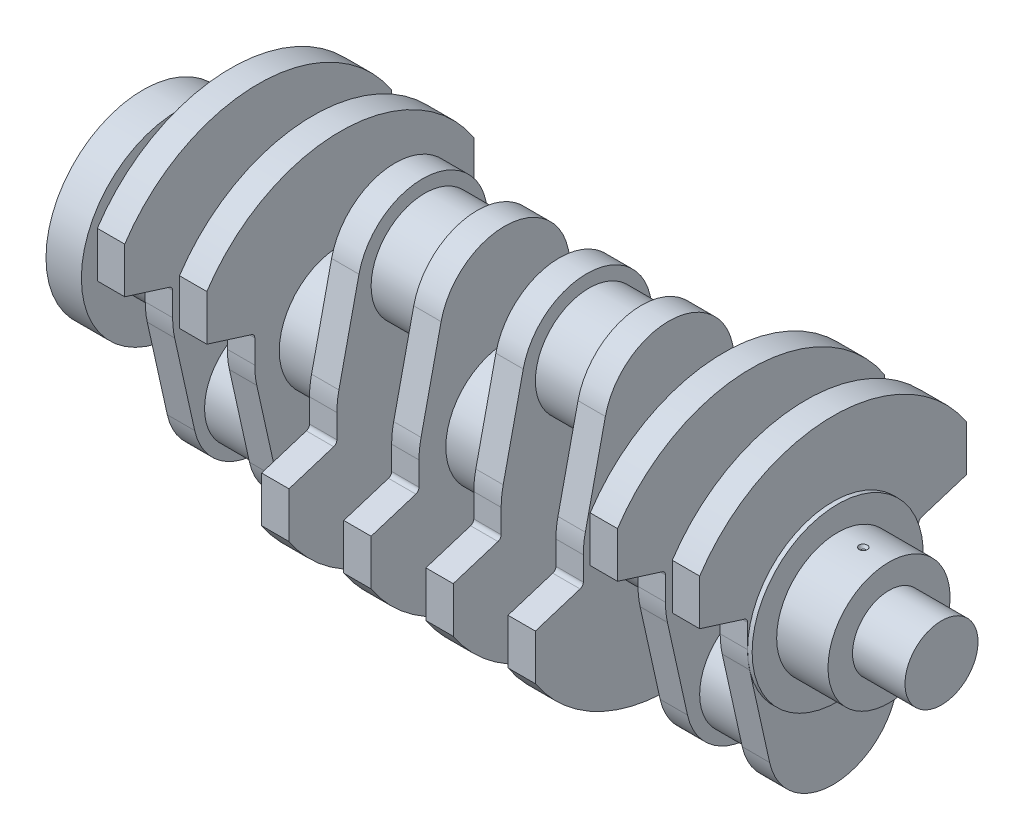
from build123d import *

# Parameters (mm, degrees)
ESBO_O1_R        = 16
EXTRUS_O1_DEPTH  = 23
ESBO_O2_R        = 26.75
EXTRUS_O2_DEPTH  = 22.5
EXTRUS_O4_DEPTH  = 12
FILETE1_R        = 2
FILETE2_R        = 2
ESBO_O10_R       = 23.5
EXTRUS_O7_DEPTH  = 23
EXTRUS_O8_DEPTH  = 12
EXTRUS_O14_DEPTH = 12
EXTRUS_O15_DEPTH = 12
EXTRUS_O16_DEPTH = 12
EXTRUS_O17_DEPTH = 12
ESBO_O20_R       = 26.75
EXTRUS_O18_DEPTH = 23
ESBO_O21_R       = 23.5
EXTRUS_O19_DEPTH = 23
ESBO_O22_R       = 26.75
EXTRUS_O21_DEPTH = 23
ESBO_O23_R       = 23.5
EXTRUS_O22_DEPTH = 23
EXTRUS_O23_DEPTH = 12
EXTRUS_O24_DEPTH = 12
ESBO_O27_R       = 26.75
EXTRUS_O25_DEPTH = 24
ESBO_O28_R       = 23.5
EXTRUS_O26_DEPTH = 24
ESBO_O29_R       = 26.75
EXTRUS_O27_DEPTH = 23
ESBO_O30_R       = 42.5
EXTRUS_O28_DEPTH = 15.5
ESBO_O31_R       = 21.5
EXTRUS_O29_DEPTH = 5.5
ESBO_O33_R       = 15
EXTRUS_O34_DEPTH = 7
EXTRUS_O34_DRAFT = 42
ESBO_O34_R       = 8
EXTRUS_O35_DEPTH = 25
ESBO_O41_R       = 37.5
EXTRUS_O42_DEPTH = 2


with BuildPart() as part:
    # Esboço1 → Extrusão1 (new body)
    with BuildSketch(Plane(origin=(0, 0, 0), x_dir=(0, 0, -1), z_dir=(1, 0, 0))):
        Circle(ESBO_O1_R)
    extrude(amount=-EXTRUS_O1_DEPTH)

    # Esboço2 → Extrusão2 (add)
    with BuildSketch(Plane.ZY.offset(23)):
        Circle(ESBO_O2_R)
    extrude(amount=EXTRUS_O2_DEPTH)

    # Esboço40 → Corte-Revolução3 (revolve, cut)
    with BuildSketch(Plane.XY, mode=Mode.PRIVATE) as corte_revolu_o3_sk:
        Polygon((-34.25, 27.978873535), (-34.25, 25.360775751), (-33.25, 25.360775751), (-31.75, 27.978873535), align=None)
    revolve(corte_revolu_o3_sk.sketch.rotate(Axis((-34.25, 27.978873535, 0), (0, -1, 0)), 90), axis=Axis((-34.25, 27.978873535, 0), (0, -1, 0)), mode=Mode.SUBTRACT)  # turned: the seam where the file's is

    # Esboço41 → Extrusão42 (add)
    with BuildSketch(Plane.ZY.offset(45.5)):
        Circle(ESBO_O41_R)
    extrude(amount=EXTRUS_O42_DEPTH)


with BuildPart() as body_2:
    # Esboço5 → Extrusão4 (new body)
    with BuildSketch(Plane.ZY.offset(47.5)):
        with BuildLine():
            Line((-36.607539576, -8.13253012), (-27.821730078, -47.680722892))
            ThreePointArc((-27.821730078, -47.680722892), (0, -70), (27.821730078, -47.680722892))
            Line((27.821730078, -47.680722892), (36.607539576, -8.13253012))
            ThreePointArc((36.607539576, -8.13253012), (37.276217177, -4.090676343), (37.5, 0))
            Line((37.5, 0), (37.5, 11.821483345))
            Line((37.5, 11.821483345), (58.5, 18.441514018))
            Line((58.5, 18.441514018), (58.5, 38.441514018))
            ThreePointArc((58.5, 38.441514018), (0, 70), (-58.5, 38.441514018))
            Line((-58.5, 38.441514018), (-58.5, 18.441514018))
            Line((-58.5, 18.441514018), (-37.5, 11.821483345))
            Line((-37.5, 11.821483345), (-37.5, 0))
            ThreePointArc((-37.5, 0), (-37.276217177, -4.090676343), (-36.607539576, -8.13253012))
        make_face()
    extrude(amount=EXTRUS_O4_DEPTH)

    # Filete1
    filete1_edges = [body_2.edges().sort_by_distance(p)[0] for p in [
        (-53.5, 11.821483345, -37.5),
    ]]
    fillet(filete1_edges, radius=FILETE1_R)

    # Filete2
    filete2_edges = [body_2.edges().sort_by_distance(p)[0] for p in [
        (-53.5, 11.821483345, 37.5),
    ]]
    fillet(filete2_edges, radius=FILETE2_R)

    # Esboço10 → Extrusão7 (add)
    with BuildSketch(Plane.ZY.offset(59.5)):
        with Locations((0, -41.5)):
            Circle(ESBO_O10_R)
    extrude(amount=EXTRUS_O7_DEPTH)


with BuildPart() as body_3:
    # Esboço9 → Extrusão8 (new body)
    with BuildSketch(Plane.ZY.offset(83.5)):
        with BuildLine():
            Line((27.821730078, -47.680722892), (36.607539576, -8.13253012))
            ThreePointArc((36.607539576, -8.13253012), (37.276217177, -4.090676343), (37.5, 0))
            Line((37.5, 0), (37.5, 10.354939827))
            ThreePointArc((37.5, 10.354939827), (37.887142651, 11.537602573), (38.89869117, 12.262406128))
            Line((38.89869117, 12.262406128), (58.5, 18.441514018))
            Line((58.5, 18.441514018), (58.5, 38.441514018))
            ThreePointArc((58.5, 38.441514018), (0, 70), (-58.5, 38.441514018))
            Line((-58.5, 38.441514018), (-58.5, 18.441514018))
            Line((-58.5, 18.441514018), (-38.89869117, 12.262406128))
            ThreePointArc((-38.89869117, 12.262406128), (-37.887142651, 11.537602573), (-37.5, 10.354939827))
            Line((-37.5, 10.354939827), (-37.5, 0))
            ThreePointArc((-37.5, 0), (-37.276217177, -4.090676343), (-36.607539576, -8.13253012))
            Line((-36.607539576, -8.13253012), (-27.821730078, -47.680722892))
            ThreePointArc((-27.821730078, -47.680722892), (0, -70), (27.821730078, -47.680722892))
        make_face()
    extrude(amount=EXTRUS_O8_DEPTH)


with BuildPart() as body_4:
    # Esboço16 → Extrusão14 (new body)
    with BuildSketch(Plane.ZY.offset(119.5)):
        with BuildLine():
            Line((37.5, 0), (37.5, -10.354939827))
            ThreePointArc((37.5, -10.354939827), (37.887142651, -11.537602573), (38.89869117, -12.262406128))
            Line((38.89869117, -12.262406128), (58.5, -18.441514018))
            Line((58.5, -18.441514018), (58.5, -38.441514018))
            ThreePointArc((58.5, -38.441514018), (0, -70), (-58.5, -38.441514018))
            Line((-58.5, -38.441514018), (-58.5, -18.441514018))
            Line((-58.5, -18.441514018), (-38.89869117, -12.262406128))
            ThreePointArc((-38.89869117, -12.262406128), (-37.887142651, -11.537602573), (-37.5, -10.354939827))
            Line((-37.5, -10.354939827), (-37.5, 0))
            ThreePointArc((-37.5, 0), (-37.276217177, 4.090676343), (-36.607539576, 8.13253012))
            Line((-36.607539576, 8.13253012), (-27.821730078, 47.680722892))
            ThreePointArc((-27.821730078, 47.680722892), (0, 70), (27.821730078, 47.680722892))
            Line((27.821730078, 47.680722892), (36.607539576, 8.13253012))
            ThreePointArc((36.607539576, 8.13253012), (37.276217177, 4.090676343), (37.5, 0))
        make_face()
    extrude(amount=EXTRUS_O14_DEPTH)


with BuildPart() as body_5:
    # Esboço17 → Extrusão15 (new body)
    with BuildSketch(Plane.ZY.offset(155.5)):
        with BuildLine():
            Line((-38.89869117, -12.262406128), (-58.5, -18.441514018))
            Line((-58.5, -18.441514018), (-58.5, -38.441514018))
            ThreePointArc((-58.5, -38.441514018), (0, -70), (58.5, -38.441514018))
            Line((58.5, -38.441514018), (58.5, -18.441514018))
            Line((58.5, -18.441514018), (38.89869117, -12.262406128))
            ThreePointArc((38.89869117, -12.262406128), (37.887142651, -11.537602573), (37.5, -10.354939827))
            Line((37.5, -10.354939827), (37.5, 0))
            ThreePointArc((37.5, 0), (37.276217177, 4.090676343), (36.607539576, 8.13253012))
            Line((36.607539576, 8.13253012), (27.821730078, 47.680722892))
            ThreePointArc((27.821730078, 47.680722892), (0, 70), (-27.821730078, 47.680722892))
            Line((-27.821730078, 47.680722892), (-36.607539576, 8.13253012))
            ThreePointArc((-36.607539576, 8.13253012), (-37.276217177, 4.090676343), (-37.5, 0))
            Line((-37.5, 0), (-37.5, -10.354939827))
            ThreePointArc((-37.5, -10.354939827), (-37.887142651, -11.537602573), (-38.89869117, -12.262406128))
        make_face()
    extrude(amount=EXTRUS_O15_DEPTH)


with BuildPart() as body_6:
    # Esboço18 → Extrusão16 (new body)
    with BuildSketch(Plane.ZY.offset(191.5)):
        with BuildLine():
            Line((-38.89869117, -12.262406128), (-58.5, -18.441514018))
            Line((-58.5, -18.441514018), (-58.5, -38.441514018))
            ThreePointArc((-58.5, -38.441514018), (0, -70), (58.5, -38.441514018))
            Line((58.5, -38.441514018), (58.5, -18.441514018))
            Line((58.5, -18.441514018), (38.89869117, -12.262406128))
            ThreePointArc((38.89869117, -12.262406128), (37.887142651, -11.537602573), (37.5, -10.354939827))
            Line((37.5, -10.354939827), (37.5, 0))
            ThreePointArc((37.5, 0), (37.276217177, 4.090676343), (36.607539576, 8.13253012))
            Line((36.607539576, 8.13253012), (27.821730078, 47.680722892))
            ThreePointArc((27.821730078, 47.680722892), (0, 70), (-27.821730078, 47.680722892))
            Line((-27.821730078, 47.680722892), (-36.607539576, 8.13253012))
            ThreePointArc((-36.607539576, 8.13253012), (-37.276217177, 4.090676343), (-37.5, 0))
            Line((-37.5, 0), (-37.5, -10.354939827))
            ThreePointArc((-37.5, -10.354939827), (-37.887142651, -11.537602573), (-38.89869117, -12.262406128))
        make_face()
    extrude(amount=EXTRUS_O16_DEPTH)


with BuildPart() as body_7:
    # Esboço19 → Extrusão17 (new body)
    with BuildSketch(Plane.ZY.offset(227.5)):
        with BuildLine():
            Line((-38.89869117, -12.262406128), (-58.5, -18.441514018))
            Line((-58.5, -18.441514018), (-58.5, -38.441514018))
            ThreePointArc((-58.5, -38.441514018), (0, -70), (58.5, -38.441514018))
            Line((58.5, -38.441514018), (58.5, -18.441514018))
            Line((58.5, -18.441514018), (38.89869117, -12.262406128))
            ThreePointArc((38.89869117, -12.262406128), (37.887142651, -11.537602573), (37.5, -10.354939827))
            Line((37.5, -10.354939827), (37.5, 0))
            ThreePointArc((37.5, 0), (37.276217177, 4.090676343), (36.607539576, 8.13253012))
            Line((36.607539576, 8.13253012), (27.821730078, 47.680722892))
            ThreePointArc((27.821730078, 47.680722892), (0, 70), (-27.821730078, 47.680722892))
            Line((-27.821730078, 47.680722892), (-36.607539576, 8.13253012))
            ThreePointArc((-36.607539576, 8.13253012), (-37.276217177, 4.090676343), (-37.5, 0))
            Line((-37.5, 0), (-37.5, -10.354939827))
            ThreePointArc((-37.5, -10.354939827), (-37.887142651, -11.537602573), (-38.89869117, -12.262406128))
        make_face()
    extrude(amount=EXTRUS_O17_DEPTH)


with BuildPart() as body_8:
    # Esboço20 → Extrusão18 (new body)
    with BuildSketch(Plane.ZY.offset(95.5)):
        Circle(ESBO_O20_R)
    extrude(amount=EXTRUS_O18_DEPTH)


with BuildPart() as body_9:
    # Esboço21 → Extrusão19 (new body)
    with BuildSketch(Plane.ZY.offset(131.5)):
        with Locations((0, 41.5)):
            Circle(ESBO_O21_R)
    extrude(amount=EXTRUS_O19_DEPTH)


with BuildPart() as body_10:
    # Esboço22 → Extrusão21 (new body)
    with BuildSketch(Plane.ZY.offset(167.5)):
        Circle(ESBO_O22_R)
    extrude(amount=EXTRUS_O21_DEPTH)


with BuildPart() as body_11:
    # Esboço23 → Extrusão22 (new body)
    with BuildSketch(Plane.ZY.offset(203.5)):
        with Locations((0, 41.5)):
            Circle(ESBO_O23_R)
    extrude(amount=EXTRUS_O22_DEPTH)


with BuildPart() as body_12:
    # Esboço25 → Extrusão23 (new body)
    with BuildSketch(Plane.ZY.offset(263.5)):
        with BuildLine():
            Line((58.5, 38.441514018), (58.5, 18.441514018))
            Line((58.5, 18.441514018), (38.89869117, 12.262406128))
            ThreePointArc((38.89869117, 12.262406128), (37.887142651, 11.537602573), (37.5, 10.354939827))
            Line((37.5, 10.354939827), (37.5, 0))
            ThreePointArc((37.5, 0), (37.276217177, -4.090676343), (36.607539576, -8.13253012))
            Line((36.607539576, -8.13253012), (27.821730078, -47.680722892))
            ThreePointArc((27.821730078, -47.680722892), (0, -70), (-27.821730078, -47.680722892))
            Line((-27.821730078, -47.680722892), (-36.607539576, -8.13253012))
            ThreePointArc((-36.607539576, -8.13253012), (-37.276217177, -4.090676343), (-37.5, 0))
            Line((-37.5, 0), (-37.5, 10.354939827))
            ThreePointArc((-37.5, 10.354939827), (-37.887142651, 11.537602573), (-38.89869117, 12.262406128))
            Line((-38.89869117, 12.262406128), (-58.5, 18.441514018))
            Line((-58.5, 18.441514018), (-58.5, 38.441514018))
            ThreePointArc((-58.5, 38.441514018), (0, 70), (58.5, 38.441514018))
        make_face()
    extrude(amount=EXTRUS_O23_DEPTH)

    # Esboço27 → Extrusão25 (add)
    with BuildSketch(Plane.ZY.offset(239.5)):
        Circle(ESBO_O27_R)
    extrude(amount=EXTRUS_O25_DEPTH)



with BuildPart() as body_13:
    # Esboço26 → Extrusão24 (new body)
    with BuildSketch(Plane.ZY.offset(299.5)):
        with BuildLine():
            Line((-58.5, 38.441514018), (-58.5, 18.441514018))
            Line((-58.5, 18.441514018), (-38.89869117, 12.262406128))
            ThreePointArc((-38.89869117, 12.262406128), (-37.887142651, 11.537602573), (-37.5, 10.354939827))
            Line((-37.5, 10.354939827), (-37.5, 0))
            ThreePointArc((-37.5, 0), (-37.276217177, -4.090676343), (-36.607539576, -8.13253012))
            Line((-36.607539576, -8.13253012), (-27.821730078, -47.680722892))
            ThreePointArc((-27.821730078, -47.680722892), (0, -70), (27.821730078, -47.680722892))
            Line((27.821730078, -47.680722892), (36.607539576, -8.13253012))
            ThreePointArc((36.607539576, -8.13253012), (37.276217177, -4.090676343), (37.5, 0))
            Line((37.5, 0), (37.5, 10.354939827))
            ThreePointArc((37.5, 10.354939827), (37.887142651, 11.537602573), (38.89869117, 12.262406128))
            Line((38.89869117, 12.262406128), (58.5, 18.441514018))
            Line((58.5, 18.441514018), (58.5, 38.441514018))
            ThreePointArc((58.5, 38.441514018), (0, 70), (-58.5, 38.441514018))
        make_face()
    extrude(amount=EXTRUS_O24_DEPTH)


with BuildPart() as body_12_1:
    add(body_12.part)

    add(body_13.part)  # Extrusão26 merges body 13
    # Esboço28 → Extrusão26 (add)
    with BuildSketch(Plane.ZY.offset(275.5)):
        with Locations(Location((0, -41.5, 0), (0, 0, 180))):  # turned: the seam where the file's is
            Circle(ESBO_O28_R)
    extrude(amount=EXTRUS_O26_DEPTH)

    # Esboço29 → Extrusão27 (add)
    with BuildSketch(Plane.ZY.offset(311.5)):
        Circle(ESBO_O29_R)
    extrude(amount=EXTRUS_O27_DEPTH)

    # Esboço30 → Extrusão28 (add)
    with BuildSketch(Plane.ZY.offset(334.5)):
        Circle(ESBO_O30_R)
    extrude(amount=EXTRUS_O28_DEPTH)

    # Esboço31 → Extrusão29 (add)
    with BuildSketch(Plane.ZY.offset(350)):
        Circle(ESBO_O31_R)
    extrude(amount=EXTRUS_O29_DEPTH)


with BuildPart() as extrus_o34_tool:
    # Esboço33 → Extrusão34 (with draft: the straight prism first)
    with BuildSketch(Plane.ZY.offset(362.5)):
        Circle(ESBO_O33_R)
    extrude(amount=-EXTRUS_O34_DEPTH)
    # Extrusão34: the draft: its side faces are tilted about the plane it starts from
    extrus_o34_sides = [extrus_o34_tool.faces().sort_by_distance(p)[0] for p in [
        (-359, 0, -15),
    ]]
    draft(extrus_o34_sides, Plane.ZY.offset(362.5), EXTRUS_O34_DRAFT)


with BuildPart() as body_12_2:
    add(body_12_1.part)

    # Extrusão34: add extrus_o34_tool
    add(extrus_o34_tool.part)

    # Esboço34 → Extrusão35 (cut)
    with BuildSketch(Plane.ZY.offset(362.5)):
        Circle(ESBO_O34_R)
    extrude(amount=-EXTRUS_O35_DEPTH, mode=Mode.SUBTRACT)


solid = Compound([part.part, body_2.part, body_3.part, body_4.part, body_5.part, body_6.part, body_7.part, body_8.part, body_9.part, body_10.part, body_11.part, body_12_2.part])
